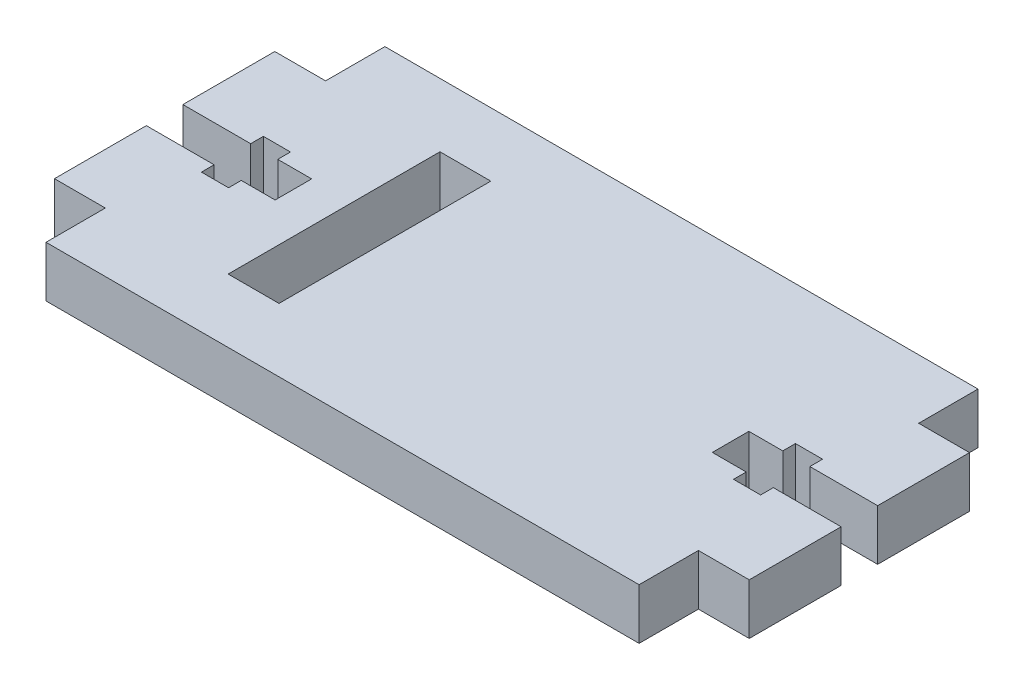
from build123d import *

# Parameters (mm, degrees)
SKETCH1_W           = 6
SKETCH1_H           = 25
BOSS_EXTRUDE1_DEPTH = 6


with BuildPart() as part:
    # Sketch1 → Boss-Extrude1 (new body)
    with BuildSketch(Plane(origin=(0, 0, 0), x_dir=(1, 0, 0), z_dir=(0, 1, 0))):
        Polygon((35, 20), (-35, 20), (-35, 13), (-41, 13), (-41, 2.156563888), (-33, 2.156563888), (-33, 3.656563888), (-29.8, 3.656563888), (-29.8, 2.156563888), (-25.8, 2.156563888), (-25.8, 1.843436112), (-25.8, -1.843436112), (-25.8, -2.156563888), (-29.8, -2.156563888), (-29.8, -3.656563888), (-33, -3.656563888), (-33, -2.156563888), (-41, -2.156563888), (-41, -13), (-35, -13), (-35, -20), (35, -20), (35, -13), (41, -13), (41, -2.156563888), (33, -2.156563888), (33, -3.656563888), (29.8, -3.656563888), (29.8, -2.156563888), (25.8, -2.156563888), (25.8, -1.843436112), (25.8, 1.843436112), (25.8, 2.156563888), (29.8, 2.156563888), (29.8, 3.656563888), (33, 3.656563888), (33, 2.156563888), (41, 2.156563888), (41, 13), (35, 13), align=None)
        with Locations((-18, 0)):
            Rectangle(SKETCH1_W, SKETCH1_H, mode=Mode.SUBTRACT)
    extrude(amount=BOSS_EXTRUDE1_DEPTH)


solid = part.part
